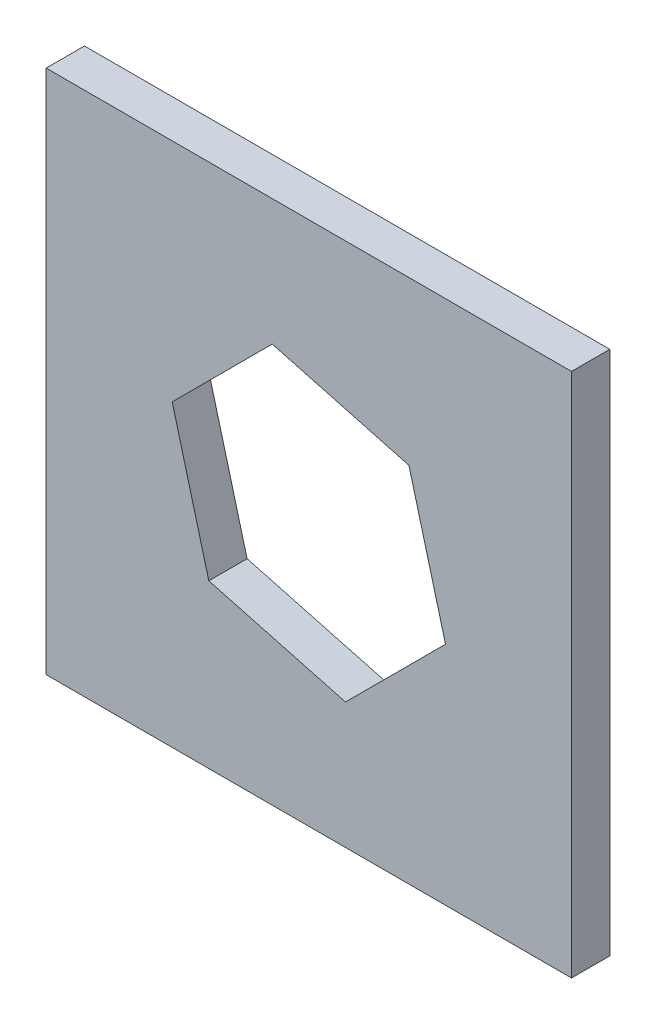
from build123d import *

# Parameters (mm, degrees)
SKETCH_1_W      = 34.3
SKETCH_1_H      = 34.3
EXTRUDE_1_DEPTH = 2.5


with BuildPart() as part:
    # 草图1 → 凸台-拉伸1 (new body)
    with BuildSketch(Plane.XY):
        Rectangle(SKETCH_1_W, SKETCH_1_H)
        Polygon((6.531972647, 6.531972647), (-2.390867926, 8.922840573), (-8.922840573, 2.390867926), (-6.531972647, -6.531972647), (2.390867926, -8.922840573), (8.922840573, -2.390867926), align=None, mode=Mode.SUBTRACT)
    extrude(amount=EXTRUDE_1_DEPTH)


solid = part.part
